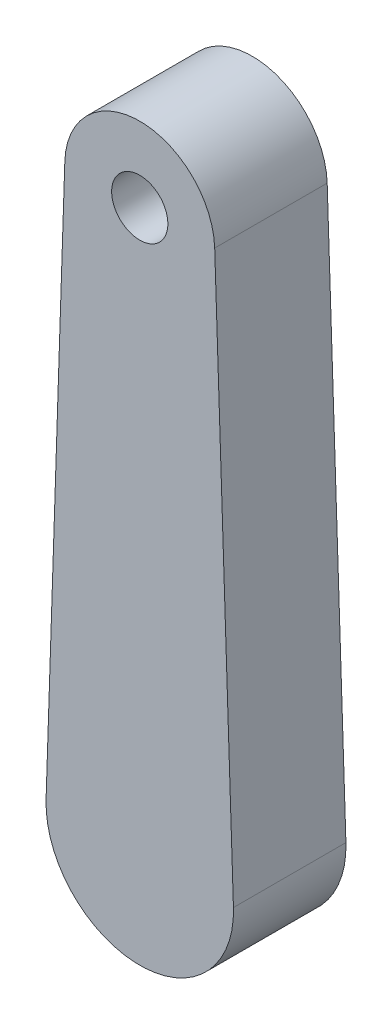
from build123d import *

# Parameters (mm, degrees)
SKETCH2_R               = 1.5
BOSS_EXTRUDE1_DEPTH     = 3
CUT_EXTRUDE1_DEPTH      = 1
CUT_EXTRUDE1_DEPTH_BACK = 35.496376621


with BuildPart() as part:
    # Sketch2 → Boss-Extrude1 (new, symmetric)
    with BuildSketch(Plane.XY):
        with BuildLine():
            Line((-4.99722145, 0.166666667), (-3.99777716, 30.133333333))
            ThreePointArc((-3.99777716, 30.133333333), (0, 34), (3.99777716, 30.133333333))
            Line((3.99777716, 30.133333333), (4.99722145, 0.166666667))
            ThreePointArc((4.99722145, 0.166666667), (0, -5), (-4.99722145, 0.166666667))
        make_face()
        with Locations((0, 30)):
            Circle(SKETCH2_R, mode=Mode.SUBTRACT)
    extrude(amount=BOSS_EXTRUDE1_DEPTH, both=True)

    # Sketch1 → Cut-Extrude1 (cut, two sides: drawn at the far end of the back side and taken through both)
    with BuildSketch(Plane.XY.offset(-CUT_EXTRUDE1_DEPTH_BACK)):
        with BuildLine():
            Line((-1.99119154, 16.1875), (-3.484585195, 0.328125))
            ThreePointArc((-3.484585195, 0.328125), (0, -3.5), (3.484585195, 0.328125))
            Line((3.484585195, 0.328125), (1.99119154, 16.1875))
            ThreePointArc((1.99119154, 16.1875), (0, 18), (-1.99119154, 16.1875))
        make_face()
    extrude(amount=CUT_EXTRUDE1_DEPTH + CUT_EXTRUDE1_DEPTH_BACK, mode=Mode.SUBTRACT)


solid = part.part
